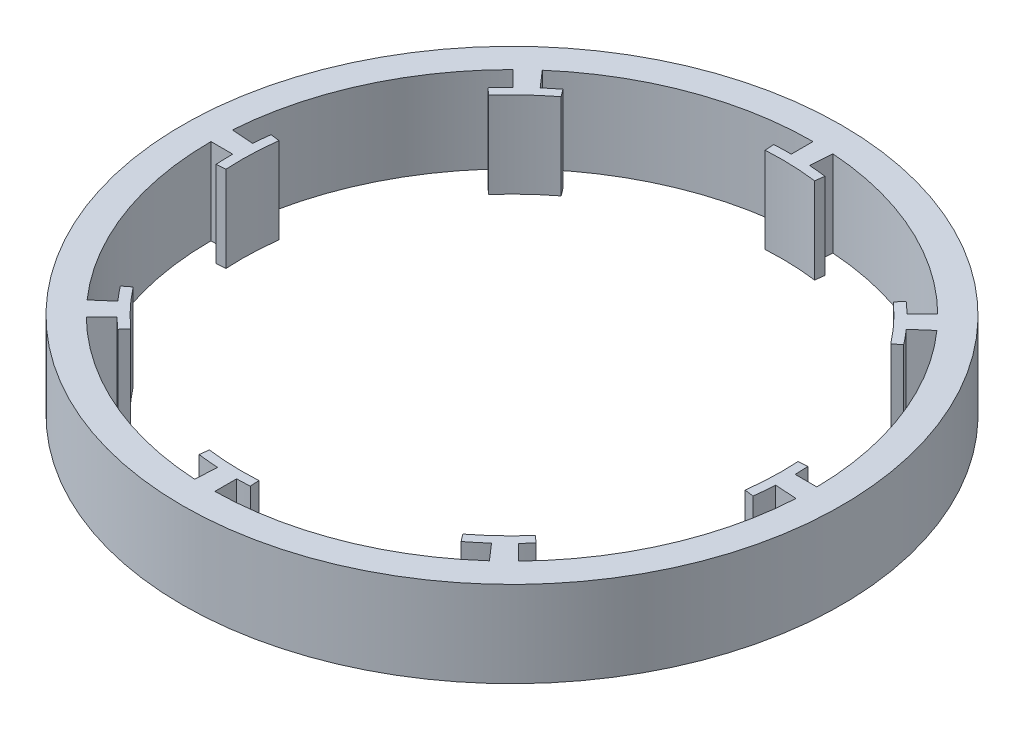
from build123d import *

# Parameters (mm, degrees)
SKETCH1_R           = 115
BOSS_EXTRUDE1_DEPTH = 30


with BuildPart() as part:
    # Sketch1 → Boss-Extrude1 (new body)
    with BuildSketch(Plane(origin=(0, 0, 0), x_dir=(1, 0, 0), z_dir=(0, 1, 0))):
        Circle(SKETCH1_R)
        with BuildLine():
            Line((0, 105.05), (0, 97.45))
            ThreePointArc((0, 97.45), (-2.975978112, 97.404548427), (-5.949180178, 97.268236106))
            Line((-5.949180178, 97.268236106), (-5.753824851, 94.074204751))
            ThreePointArc((-5.753824851, 94.074204751), (3.207077785, 94.195420016), (12.138984977, 93.465007055))
            Line((12.138984977, 93.465007055), (12.551130886, 96.638354774))
            ThreePointArc((12.551130886, 96.638354774), (9.59408525, 96.976574636), (6.628090075, 97.224332973))
            Line((6.628090075, 97.224332973), (7.145006284, 104.806733492))
            ThreePointArc((7.145006284, 104.806733492), (43.173122748, 95.768387123), (73.803507095, 74.756570551))
            Line((73.803507095, 74.756570551), (68.429376346, 69.382439802))
            ThreePointArc((68.429376346, 69.382439802), (66.525250753, 71.210206517), (64.572323699, 72.985734991))
            Line((64.572323699, 72.985734991), (62.451939544, 70.589076684))
            ThreePointArc((62.451939544, 70.589076684), (68.8739667, 64.338473801), (74.673298886, 57.506181698))
            Line((74.673298886, 57.506181698), (77.208625745, 59.458646222))
            ThreePointArc((77.208625745, 59.458646222), (75.137185677, 62.055667175), (72.978432671, 64.580576529))
            Line((72.978432671, 64.580576529), (78.705648152, 69.576745031))
            ThreePointArc((78.705648152, 69.576745031), (98.00273537, 37.828115999), (105.041353, 1.347835265))
            Line((105.041353, 1.347835265), (97.44067857, 1.347835265))
            ThreePointArc((97.44067857, 1.347835265), (97.381638194, 3.649526366), (97.268236106, 5.949180178))
            Line((97.268236106, 5.949180178), (94.074204751, 5.753824851))
            ThreePointArc((94.074204751, 5.753824851), (94.206040936, 2.87825487), (94.25, 0))
            ThreePointArc((94.25, 0), (94.053547022, -6.082170053), (93.465007055, -12.138984977))
            Line((93.465007055, -12.138984977), (96.638354774, -12.551130886))
            ThreePointArc((96.638354774, -12.551130886), (97.040462342, -8.92475033), (97.306537269, -5.285858937))
            Line((97.306537269, -5.285858937), (104.889607544, -5.802820805))
            ThreePointArc((104.889607544, -5.802820805), (96.234836599, -42.123137642), (75.423107292, -73.122208571))
            Line((75.423107292, -73.122208571), (70.048400827, -67.747502106))
            ThreePointArc((70.048400827, -67.747502106), (71.534686983, -66.176212178), (72.985734991, -64.572323699))
            Line((72.985734991, -64.572323699), (70.589076684, -62.451939544))
            ThreePointArc((70.589076684, -62.451939544), (64.338473801, -68.8739667), (57.506181698, -74.673298886))
            Line((57.506181698, -74.673298886), (59.458646222, -77.208625745))
            ThreePointArc((59.458646222, -77.208625745), (62.396629618, -74.854279185), (65.241478394, -72.388203438))
            Line((65.241478394, -72.388203438), (70.238137515, -78.115981326))
            ThreePointArc((70.238137515, -78.115981326), (38.241100725, -97.842325787), (1.347835265, -105.041353))
            Line((1.347835265, -105.041353), (1.347835265, -97.44067857))
            ThreePointArc((1.347835265, -97.44067857), (3.649526366, -97.381638194), (5.949180178, -97.268236106))
            Line((5.949180178, -97.268236106), (5.753824851, -94.074204751))
            ThreePointArc((5.753824851, -94.074204751), (-3.207077785, -94.195420016), (-12.138984977, -93.465007055))
            Line((-12.138984977, -93.465007055), (-12.551130886, -96.638354774))
            ThreePointArc((-12.551130886, -96.638354774), (-8.97039747, -97.036253376), (-5.377403168, -97.301521238))
            Line((-5.377403168, -97.301521238), (-5.894359023, -104.884503296))
            ThreePointArc((-5.894359023, -104.884503296), (-42.601180134, -96.024173786), (-73.803507095, -74.756570551))
            Line((-73.803507095, -74.756570551), (-68.429376346, -69.382439802))
            ThreePointArc((-68.429376346, -69.382439802), (-66.525250753, -71.210206517), (-64.572323699, -72.985734991))
            Line((-64.572323699, -72.985734991), (-62.451939544, -70.589076684))
            ThreePointArc((-62.451939544, -70.589076684), (-68.8739667, -64.338473801), (-74.673298886, -57.506181698))
            Line((-74.673298886, -57.506181698), (-77.208625745, -59.458646222))
            ThreePointArc((-77.208625745, -59.458646222), (-75.178448793, -62.005671814), (-73.064286712, -64.48342816))
            Line((-73.064286712, -64.48342816), (-78.791456749, -69.479557018))
            ThreePointArc((-78.791456749, -69.479557018), (-98.2663346, -37.137985733), (-105.05, 0))
            Line((-105.05, 0), (-97.45, 0))
            ThreePointArc((-97.45, 0), (-97.404548427, -2.975978112), (-97.268236106, -5.949180178))
            Line((-97.268236106, -5.949180178), (-94.074204751, -5.753824851))
            ThreePointArc((-94.074204751, -5.753824851), (-94.195420016, 3.207077785), (-93.465007055, 12.138984977))
            Line((-93.465007055, 12.138984977), (-96.638354774, 12.551130886))
            ThreePointArc((-96.638354774, 12.551130886), (-96.972051222, 9.639698217), (-97.218054759, 6.71954826))
            Line((-97.218054759, 6.71954826), (-104.800458391, 7.236464681))
            ThreePointArc((-104.800458391, 7.236464681), (-95.552521618, 43.64880425), (-74.083919205, 74.478691014))
            Line((-74.083919205, 74.478691014), (-68.709887215, 69.104659024))
            ThreePointArc((-68.709887215, 69.104659024), (-70.88404513, 66.872674883), (-72.985734991, 64.572323699))
            Line((-72.985734991, 64.572323699), (-70.589076684, 62.451939544))
            ThreePointArc((-70.589076684, 62.451939544), (-64.338473801, 68.8739667), (-57.506181698, 74.673298886))
            Line((-57.506181698, 74.673298886), (-59.458646222, 77.208625745))
            ThreePointArc((-59.458646222, 77.208625745), (-61.663262597, 75.459555697), (-63.816455081, 73.647556381))
            Line((-63.816455081, 73.647556381), (-68.812532618, 79.374667588))
            ThreePointArc((-68.812532618, 79.374667588), (-36.72324652, 98.422079154), (0, 105.05))
        make_face(mode=Mode.SUBTRACT)
    extrude(amount=BOSS_EXTRUDE1_DEPTH)


solid = part.part
